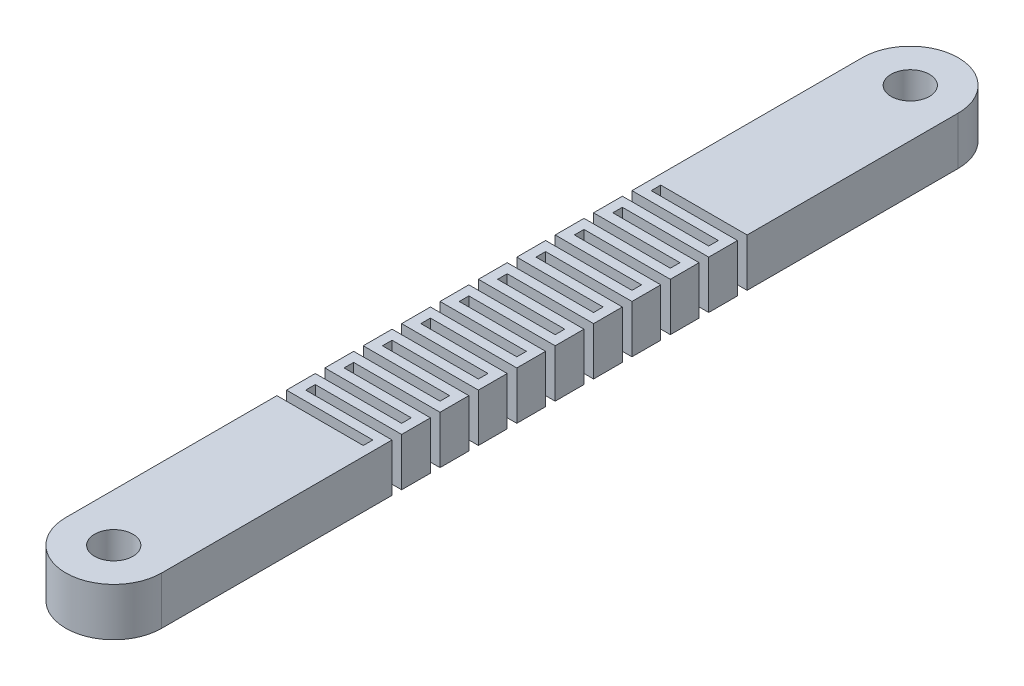
from build123d import *

# Parameters (mm, degrees)
SKETCH1_R           = 2
BOSS_EXTRUDE1_DEPTH = 5
SKETCH2_W           = 18
SKETCH2_H           = 1
CUT_EXTRUDE1_DEPTH  = 6
LPATTERN1_COUNT     = 5
LPATTERN1_PITCH     = 4
LPATTERN1_COL_COUNT = 6
LPATTERN1_COL_PITCH = 4


with BuildPart() as part:
    # Sketch1 → Boss-Extrude1 (new body)
    with BuildSketch(Plane(origin=(0, 0, 0), x_dir=(1, 0, 0), z_dir=(0, 1, 0))):
        with BuildLine():
            Line((5, 41.5), (5, -41.5))
            ThreePointArc((5, -41.5), (0, -46.5), (-5, -41.5))
            Line((-5, -41.5), (-5, 41.5))
            ThreePointArc((-5, 41.5), (0, 46.5), (5, 41.5))
        make_face()
        with Locations((0, 41.5)):
            Circle(SKETCH1_R, mode=Mode.SUBTRACT)
        with Locations((0, -41.5)):
            Circle(SKETCH1_R, mode=Mode.SUBTRACT)
    extrude(amount=BOSS_EXTRUDE1_DEPTH)

    # Sketch2 → Cut-Extrude1 (cut, through all)
    with BuildSketch(Plane(origin=(0, 5, 0), x_dir=(1, 0, 0), z_dir=(0, 1, 0))):
        with Locations((5, 3)):
            Rectangle(SKETCH2_W, SKETCH2_H)
        with Locations((-5, 1)):
            Rectangle(SKETCH2_W, SKETCH2_H)
    cut_extrude1 = extrude(amount=-CUT_EXTRUDE1_DEPTH, mode=Mode.SUBTRACT)

    # LPattern1: Cut-Extrude1 ×5
    with Locations(*[(0, 0, -i * LPATTERN1_PITCH) for i in range(1, LPATTERN1_COUNT)]):
        add(cut_extrude1, mode=Mode.SUBTRACT)

    # LPattern1 col: Cut-Extrude1 ×6
    with Locations(*[(0, 0, i * LPATTERN1_COL_PITCH) for i in range(1, LPATTERN1_COL_COUNT)]):
        add(cut_extrude1, mode=Mode.SUBTRACT)


solid = part.part
